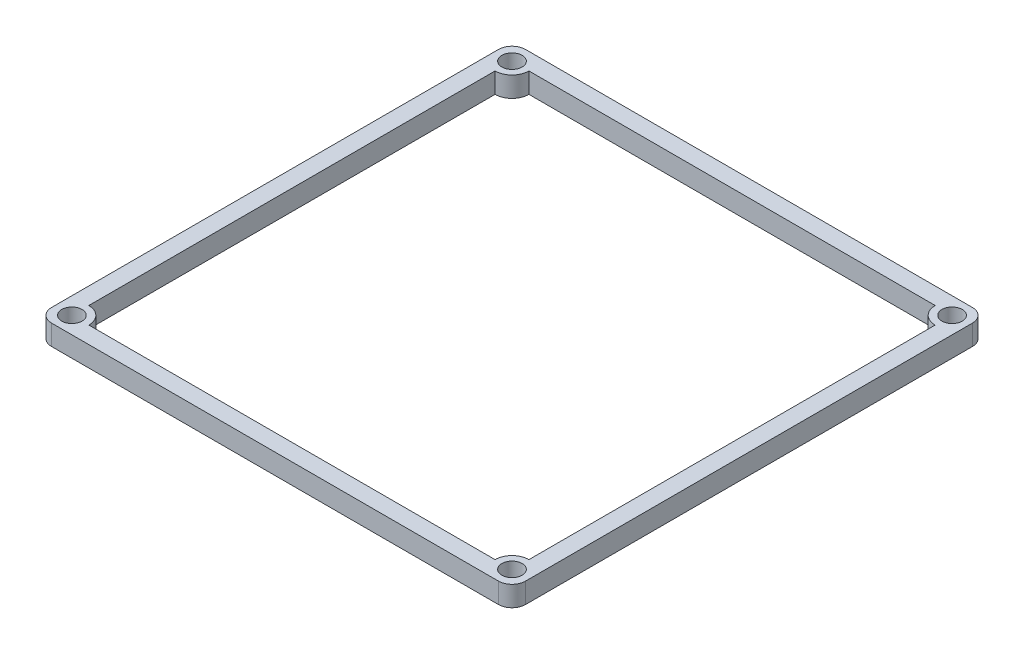
from build123d import *

# Parameters (mm, degrees)
SKETCH1_W           = 70
SKETCH1_H           = 70
SKETCH1_R           = 1.5
BOSS_EXTRUDE1_DEPTH = 3
FILLET1_R           = 2
CUT_EXTRUDE1_DEPTH  = 4


with BuildPart() as part:
    # Sketch1 → Boss-Extrude1 (new body)
    with BuildSketch(Plane(origin=(0, 0, 0), x_dir=(1, 0, 0), z_dir=(0, 1, 0))):
        Rectangle(SKETCH1_W, SKETCH1_H)
        with Locations((-32.5, 32.5)):
            Circle(SKETCH1_R, mode=Mode.SUBTRACT)
        with Locations((32.5, 32.5)):
            Circle(SKETCH1_R, mode=Mode.SUBTRACT)
        with Locations((32.5, -32.5)):
            Circle(SKETCH1_R, mode=Mode.SUBTRACT)
        with Locations((-32.5, -32.5)):
            Circle(SKETCH1_R, mode=Mode.SUBTRACT)
    extrude(amount=BOSS_EXTRUDE1_DEPTH)

    # Fillet1
    fillet1_edges = [part.edges().sort_by_distance(p)[0] for p in [
        (35, 1.5, 35),
        (-35, 1.5, 35),
        (-35, 1.5, -35),
        (35, 1.5, -35),
    ]]
    fillet(fillet1_edges, radius=FILLET1_R)

    # Sketch2 → Cut-Extrude1 (cut, through all)
    with BuildSketch(Plane(origin=(0, 3, 0), x_dir=(1, 0, 0), z_dir=(0, 1, 0))):
        with BuildLine():
            Line((30, -32.5), (-30, -32.5))
            ThreePointArc((-30, -32.5), (-30.732233047, -30.732233047), (-32.5, -30))
            Line((-32.5, -30), (-32.5, 30))
            ThreePointArc((-32.5, 30), (-30.732233047, 30.732233047), (-30, 32.5))
            Line((-30, 32.5), (30, 32.5))
            ThreePointArc((30, 32.5), (30.732233047, 30.732233047), (32.5, 30))
            Line((32.5, 30), (32.5, -30))
            ThreePointArc((32.5, -30), (30.732233047, -30.732233047), (30, -32.5))
        make_face()
    extrude(amount=-CUT_EXTRUDE1_DEPTH, mode=Mode.SUBTRACT)


solid = part.part
